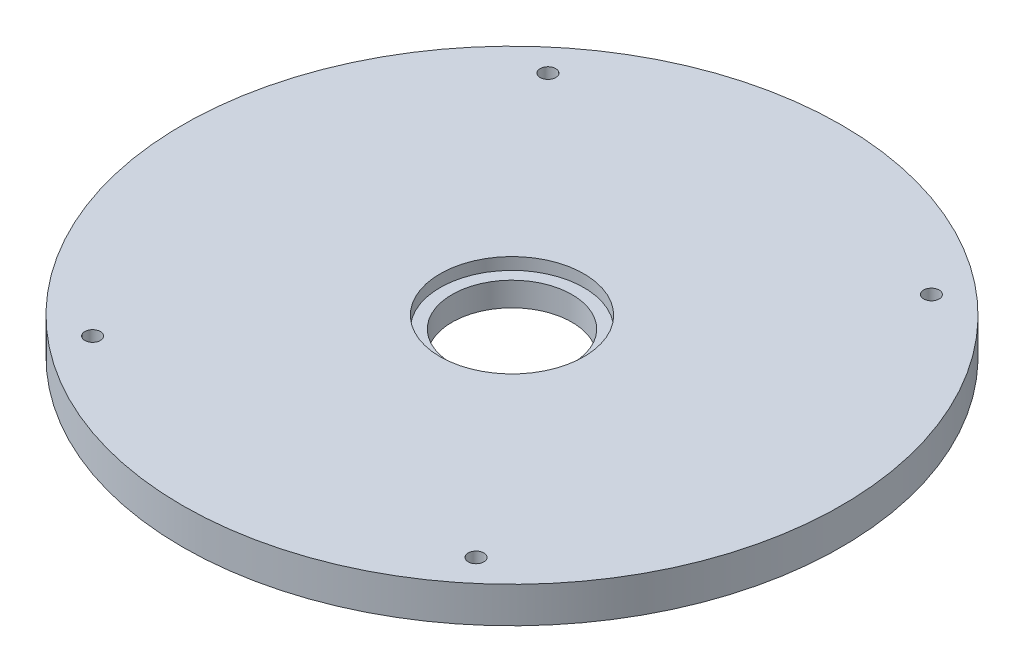
from build123d import *

# Parameters (mm, degrees)
BASESKETCH_R              = 137.5
BASE_DEPTH                = 15
MOUNTINGHOLES_R           = 3.25
CUT_EXTRUDE1_DEPTH        = 15
BEARINGJ1_R               = 25
CUT_EXTRUDE3_DEPTH        = 15
CUT_EXTRUDE4_START        = 15
BEARINGRADIALCONSTRAINT_R = 30
CUT_EXTRUDE4_DEPTH        = 5


with BuildPart() as part:
    # BaseSketch → Base (new body)
    with BuildSketch(Plane(origin=(0, 0, 0), x_dir=(1, 0, 0), z_dir=(0, 1, 0))):
        Circle(BASESKETCH_R)
    extrude(amount=BASE_DEPTH)

    # MountingHoles → Cut-Extrude1 (cut)
    with BuildSketch(Plane(origin=(0, 0, 0), x_dir=(1, 0, 0), z_dir=(0, 1, 0))):
        with Locations((-80, 95)):
            Circle(MOUNTINGHOLES_R)
        with Locations((-80, -95)):
            Circle(MOUNTINGHOLES_R)
        with Locations((80, -95)):
            Circle(MOUNTINGHOLES_R)
        with Locations((80, 95)):
            Circle(MOUNTINGHOLES_R)
    extrude(amount=CUT_EXTRUDE1_DEPTH, mode=Mode.SUBTRACT)

    # BearingJ1 → Cut-Extrude3 (cut)
    with BuildSketch(Plane(origin=(0, 0, 0), x_dir=(1, 0, 0), z_dir=(0, 1, 0))):
        Circle(BEARINGJ1_R)
    extrude(amount=CUT_EXTRUDE3_DEPTH, mode=Mode.SUBTRACT)

    # BearingRadialConstraint → Cut-Extrude4 (cut)
    with BuildSketch(Plane(origin=(0, 0, 0), x_dir=(1, 0, 0), z_dir=(0, 1, 0)).offset(CUT_EXTRUDE4_START)):
        Circle(BEARINGRADIALCONSTRAINT_R)
    extrude(amount=-CUT_EXTRUDE4_DEPTH, mode=Mode.SUBTRACT)


solid = part.part
